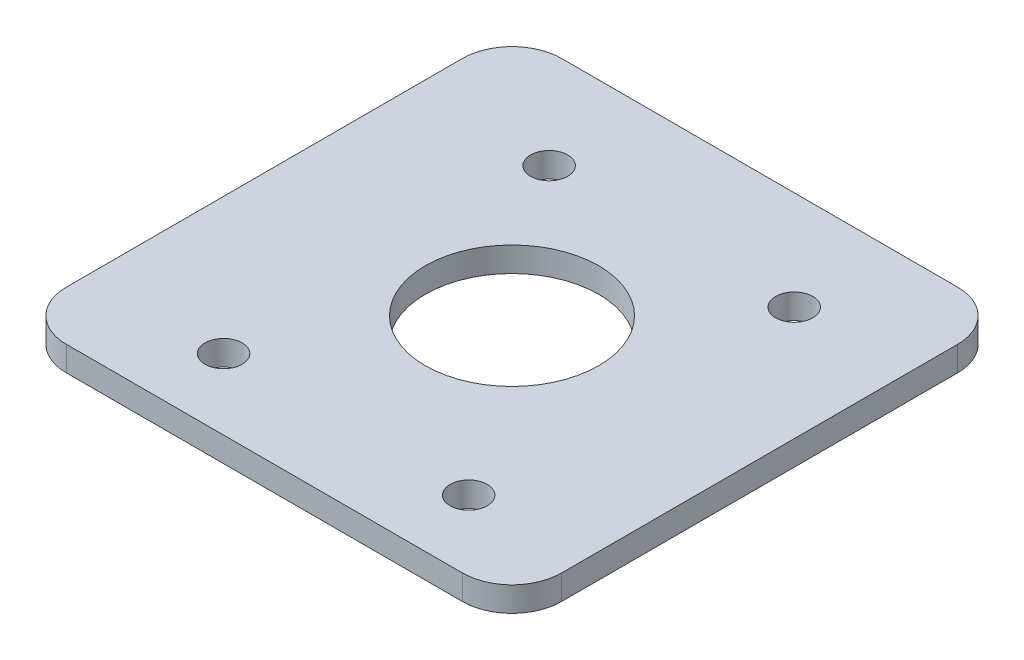
from build123d import *

# Parameters (mm, degrees)
SKETCH2_W           = 40
SKETCH2_H           = 40
SKETCH2_R           = 7
SKETCH2_R_2         = 1.5
BOSS_EXTRUDE1_DEPTH = 2
FILLET1_R           = 4


with BuildPart() as part:
    # Sketch2 → Boss-Extrude1 (new body)
    with BuildSketch(Plane(origin=(0, 0, 0), x_dir=(1, 0, 0), z_dir=(0, 1, 0))):
        Rectangle(SKETCH2_W, SKETCH2_H)
        Circle(SKETCH2_R, mode=Mode.SUBTRACT)
        with Locations((-9, 12)):
            Circle(SKETCH2_R_2, mode=Mode.SUBTRACT)
        with Locations((-9, -14.3)):
            Circle(SKETCH2_R_2, mode=Mode.SUBTRACT)
        with Locations((10.8, -14.3)):
            Circle(SKETCH2_R_2, mode=Mode.SUBTRACT)
        with Locations((10.8, 12)):
            Circle(SKETCH2_R_2, mode=Mode.SUBTRACT)
    extrude(amount=BOSS_EXTRUDE1_DEPTH)

    # Fillet1
    fillet1_edges = [part.edges().sort_by_distance(p)[0] for p in [
        (20, 1, 20),
        (-20, 1, 20),
        (-20, 1, -20),
        (20, 1, -20),
    ]]
    fillet(fillet1_edges, radius=FILLET1_R)


solid = part.part
